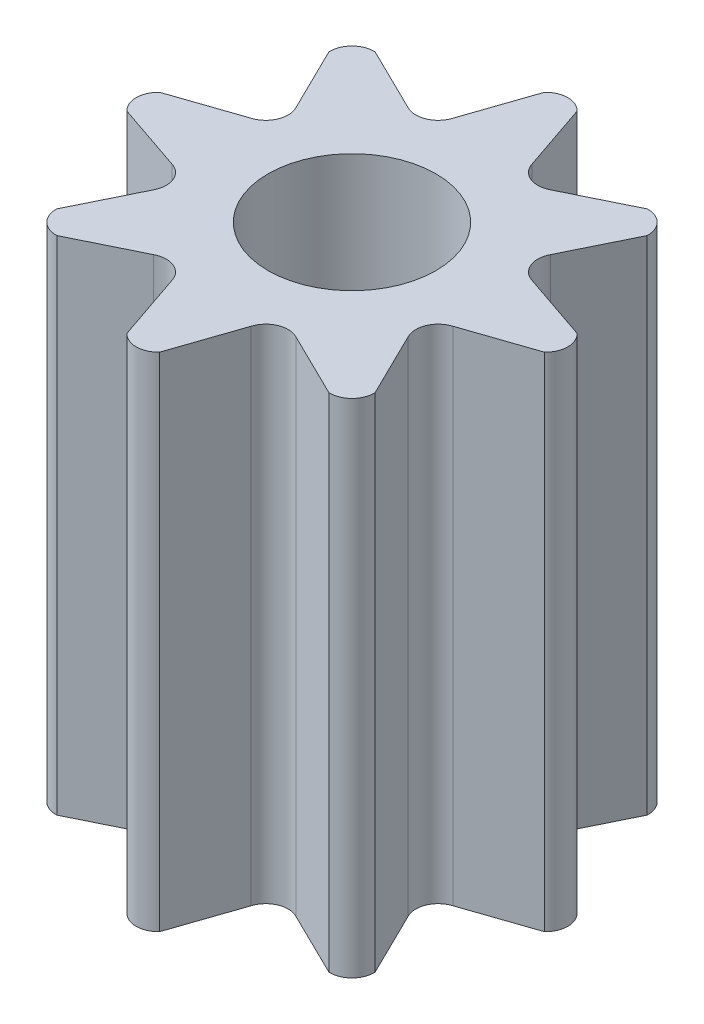
from build123d import *

# Parameters (mm, degrees)
SKETCH1_R           = 0.7525
BOSS_EXTRUDE1_DEPTH = 4.5


with BuildPart() as part:
    # Sketch1 → Boss-Extrude1 (new body)
    with BuildSketch(Plane(origin=(0, 0, 0), x_dir=(1, 0, 0), z_dir=(0, 1, 0))):
        with BuildLine():
            Line((-0.146366384, 1.87135971), (-0.355366692, 1.259293266))
            ThreePointArc((-0.355366692, 1.259293266), (-0.398631621, 1.183964502), (-0.469753326, 1.13408485))
            ThreePointArc((-0.469753326, 1.13408485), (-0.555314206, 1.11906445), (-0.63917261, 1.141737006))
            Line((-0.63917261, 1.141737006), (-1.219754478, 1.426747804))
            ThreePointArc((-1.219754478, 1.426747804), (-1.36829594, 1.36829594), (-1.426747804, 1.219754478))
            Line((-1.426747804, 1.219754478), (-1.141737006, 0.63917261))
            ThreePointArc((-1.141737006, 0.63917261), (-1.11906445, 0.555314206), (-1.13408485, 0.469753326))
            ThreePointArc((-1.13408485, 0.469753326), (-1.183964502, 0.398631621), (-1.259293266, 0.355366692))
            Line((-1.259293266, 0.355366692), (-1.87135971, 0.146366384))
            ThreePointArc((-1.87135971, 0.146366384), (-1.935062676, 0), (-1.87135971, -0.146366384))
            Line((-1.87135971, -0.146366384), (-1.259293266, -0.355366692))
            ThreePointArc((-1.259293266, -0.355366692), (-1.183964502, -0.398631621), (-1.13408485, -0.469753326))
            ThreePointArc((-1.13408485, -0.469753326), (-1.11906445, -0.555314206), (-1.141737006, -0.63917261))
            Line((-1.141737006, -0.63917261), (-1.426747804, -1.219754478))
            ThreePointArc((-1.426747804, -1.219754478), (-1.36829594, -1.36829594), (-1.219754478, -1.426747804))
            Line((-1.219754478, -1.426747804), (-0.63917261, -1.141737006))
            ThreePointArc((-0.63917261, -1.141737006), (-0.555314206, -1.11906445), (-0.469753326, -1.13408485))
            ThreePointArc((-0.469753326, -1.13408485), (-0.398631621, -1.183964502), (-0.355366692, -1.259293266))
            Line((-0.355366692, -1.259293266), (-0.146366384, -1.87135971))
            ThreePointArc((-0.146366384, -1.87135971), (0, -1.935062676), (0.146366384, -1.87135971))
            Line((0.146366384, -1.87135971), (0.355366692, -1.259293266))
            ThreePointArc((0.355366692, -1.259293266), (0.398631621, -1.183964502), (0.469753326, -1.13408485))
            ThreePointArc((0.469753326, -1.13408485), (0.555314206, -1.11906445), (0.63917261, -1.141737006))
            Line((0.63917261, -1.141737006), (1.219754478, -1.426747804))
            ThreePointArc((1.219754478, -1.426747804), (1.36829594, -1.36829594), (1.426747804, -1.219754478))
            Line((1.426747804, -1.219754478), (1.141737006, -0.63917261))
            ThreePointArc((1.141737006, -0.63917261), (1.11906445, -0.555314206), (1.13408485, -0.469753326))
            ThreePointArc((1.13408485, -0.469753326), (1.183964502, -0.398631621), (1.259293266, -0.355366692))
            Line((1.259293266, -0.355366692), (1.87135971, -0.146366384))
            ThreePointArc((1.87135971, -0.146366384), (1.935062676, 0), (1.87135971, 0.146366384))
            Line((1.87135971, 0.146366384), (1.259293266, 0.355366692))
            ThreePointArc((1.259293266, 0.355366692), (1.183964502, 0.398631621), (1.13408485, 0.469753326))
            ThreePointArc((1.13408485, 0.469753326), (1.11906445, 0.555314206), (1.141737006, 0.63917261))
            Line((1.141737006, 0.63917261), (1.426747804, 1.219754478))
            ThreePointArc((1.426747804, 1.219754478), (1.36829594, 1.36829594), (1.219754478, 1.426747804))
            Line((1.219754478, 1.426747804), (0.63917261, 1.141737006))
            ThreePointArc((0.63917261, 1.141737006), (0.555314206, 1.11906445), (0.469753326, 1.13408485))
            ThreePointArc((0.469753326, 1.13408485), (0.398631621, 1.183964502), (0.355366692, 1.259293266))
            Line((0.355366692, 1.259293266), (0.146366384, 1.87135971))
            ThreePointArc((0.146366384, 1.87135971), (0, 1.935062676), (-0.146366384, 1.87135971))
        make_face()
        Circle(SKETCH1_R, mode=Mode.SUBTRACT)
    extrude(amount=BOSS_EXTRUDE1_DEPTH)


solid = part.part
